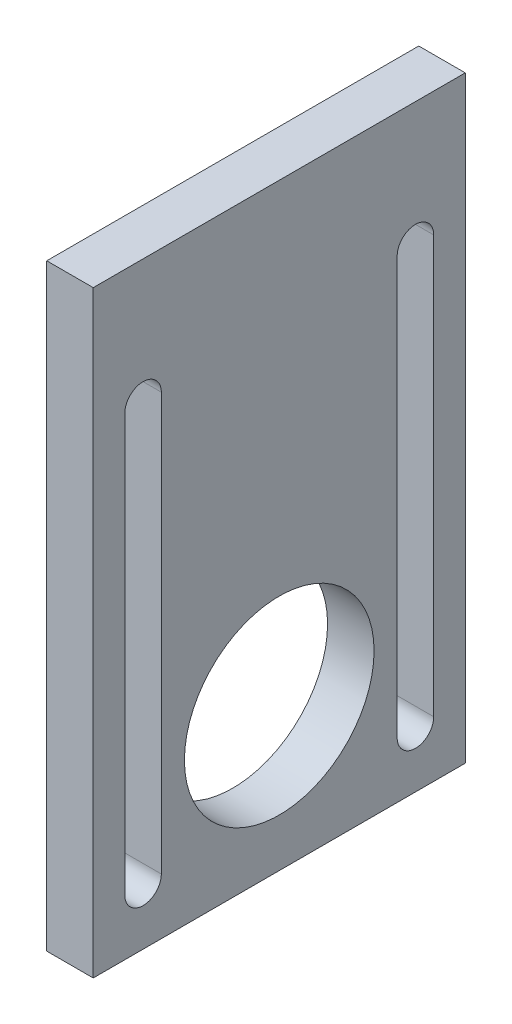
from build123d import *

# Parameters (mm, degrees)
SKETCH1_W           = 56
SKETCH1_H           = 90
BOSS_EXTRUDE1_DEPTH = 7
SKETCH2_R           = 14.275
CUT_EXTRUDE1_DEPTH  = 8
CUT_EXTRUDE2_DEPTH  = 8


with BuildPart() as part:
    # Sketch1 → Boss-Extrude1 (new body)
    with BuildSketch(Plane(origin=(0, 0, 0), x_dir=(0, 0, -1), z_dir=(1, 0, 0))):
        with Locations((28, 45)):
            Rectangle(SKETCH1_W, SKETCH1_H)
    extrude(amount=BOSS_EXTRUDE1_DEPTH)

    # Sketch2 → Cut-Extrude1 (cut, through all)
    with BuildSketch(Plane(origin=(7, 0, 0), x_dir=(0, 0, -1), z_dir=(1, 0, 0))):
        with Locations((28, 21.516289278)):
            Circle(SKETCH2_R)
    extrude(amount=-CUT_EXTRUDE1_DEPTH, mode=Mode.SUBTRACT)

    # Sketch3 → Cut-Extrude2 (cut, through all)
    with BuildSketch(Plane(origin=(7, 0, 0), x_dir=(0, 0, -1), z_dir=(1, 0, 0))):
        with BuildLine():
            Line((10.25, 71.244817418), (10.25, 8.434985259))
            ThreePointArc((10.25, 8.434985259), (7.5, 5.684985259), (4.75, 8.434985259))
            Line((4.75, 8.434985259), (4.75, 71.244817418))
            ThreePointArc((4.75, 71.244817418), (7.5, 73.994817418), (10.25, 71.244817418))
        make_face()
        with BuildLine():
            Line((45.75, 8.434985259), (45.75, 71.244817418))
            ThreePointArc((45.75, 71.244817418), (48.5, 73.994817418), (51.25, 71.244817418))
            Line((51.25, 71.244817418), (51.25, 8.434985259))
            ThreePointArc((51.25, 8.434985259), (48.5, 5.684985259), (45.75, 8.434985259))
        make_face()
    extrude(amount=-CUT_EXTRUDE2_DEPTH, mode=Mode.SUBTRACT)


solid = part.part
